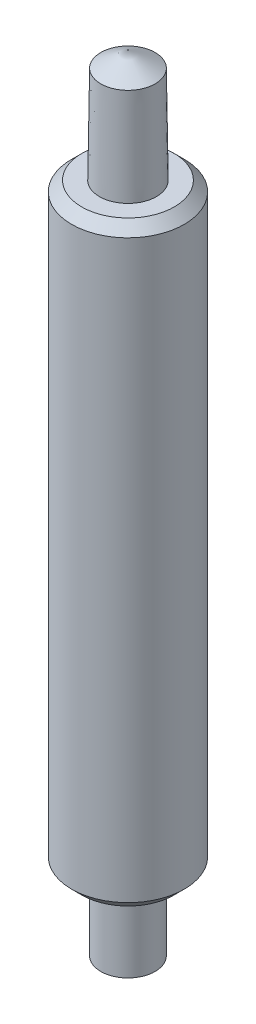
from build123d import *


with BuildPart() as part:
    # Sketch1 → Revolve1 (revolve)
    with BuildSketch(Plane(origin=(0, 0, 0), x_dir=(-1, 0, 0), z_dir=(0, 0, -1))):
        Polygon((-0.135, 0.07339164), (0, 0), (0, 3.97), (-0.135, 3.892057714), (-0.1415126, 3.41), (-0.23, 3.41), (-0.28, 3.36), (-0.28, 0.5), (-0.23, 0.45), (-0.135, 0.45), align=None)
    revolve(axis=Axis((0, 0, 0), (0, 1, 0)))


solid = part.part
